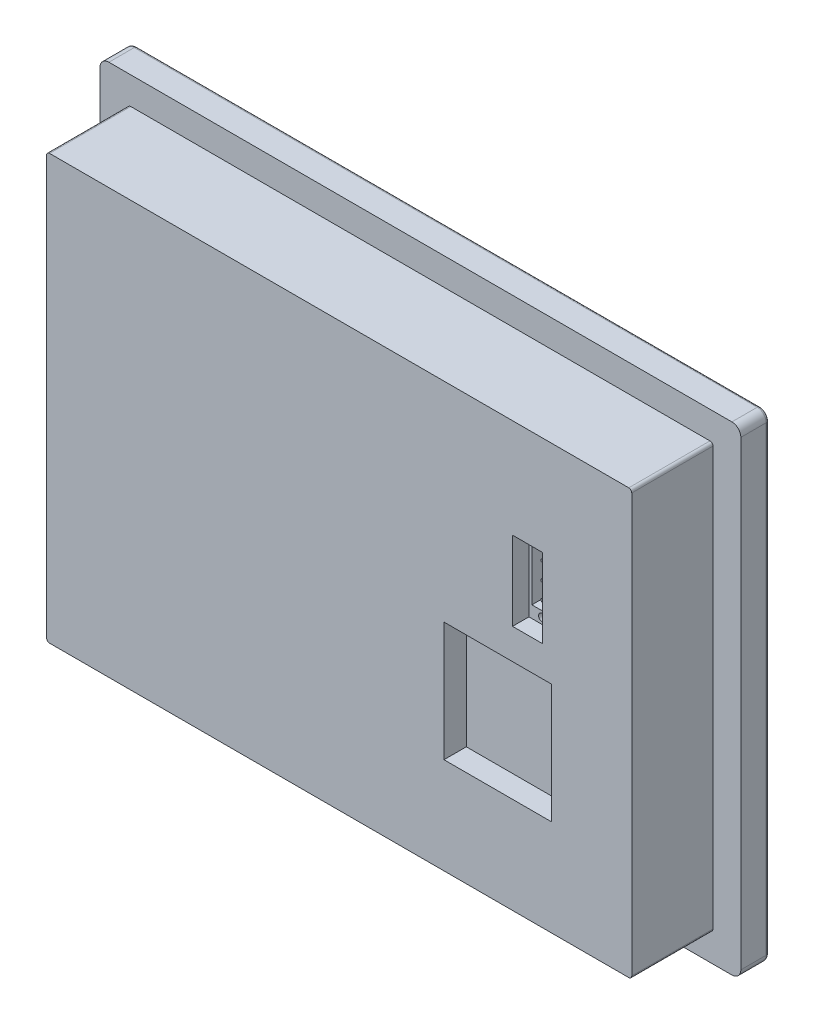
from build123d import *

# Parameters (mm, degrees)
IZIM1_W                     = 215
IZIM1_H                     = 160.7
Y_KSEKLIK_EKSTR_ZYON1_DEPTH = 9.5
IZIM2_W                     = 196.3
IZIM2_H                     = 142.3
Y_KSEKLIK_EKSTR_ZYON2_DEPTH = 27.24
IZIM3_W                     = 10
IZIM3_H                     = 26.5
IZIM3_W_2                   = 9
IZIM3_H_2                   = 25.5
KES_EKSTR_ZYON1_DEPTH       = 15
IZIM4_W                     = 9
IZIM4_H                     = 25.5
KES_EKSTR_ZYON2_DEPTH       = 5
IZIM5_R                     = 0.5
KES_EKSTR_ZYON3_DEPTH       = 5
M3_DI_LI_DELIK1_D           = 2.5
M3_DI_LI_DELIK1_DEPTH       = 8.5
M3_DI_LI_DELIK1_TIP         = 0.751075774
IZIM8_W                     = 155
IZIM8_H                     = 86
KES_EKSTR_ZYON4_DEPTH       = 0.05
KES_EKSTR_ZYON5_DEPTH       = 0.005
RADYUS1_R                   = 3
RADYUS2_R                   = 1
IZIM10_W                    = 36
IZIM10_H                    = 40
KES_EKSTR_ZYON6_DEPTH       = 7.5
RADYUS3_R                   = 1


with BuildPart() as part:
    # Çizim1 → Yükseklik-Ekstrüzyon1 (new body)
    with BuildSketch(Plane.XY):
        Rectangle(IZIM1_W, IZIM1_H)
    extrude(amount=Y_KSEKLIK_EKSTR_ZYON1_DEPTH)

    # Çizim2 → Yükseklik-Ekstrüzyon2 (add)
    with BuildSketch(Plane.XY.offset(9.5)):
        Rectangle(IZIM2_W, IZIM2_H)
    extrude(amount=Y_KSEKLIK_EKSTR_ZYON2_DEPTH)

    # Çizim3 → Kes-Ekstrüzyon1 (cut)
    with BuildSketch(Plane.XY.offset(36.74)):
        with Locations((63.15, 24.65)):
            Rectangle(IZIM3_W, IZIM3_H)
        with Locations((63.15, 24.65)):
            Rectangle(IZIM3_W_2, IZIM3_H_2, mode=Mode.SUBTRACT)
    extrude(amount=-KES_EKSTR_ZYON1_DEPTH, mode=Mode.SUBTRACT)

    # Çizim4 → Kes-Ekstrüzyon2 (cut)
    with BuildSketch(Plane.XY.offset(36.74)):
        with Locations((63.15, 24.65)):
            Rectangle(IZIM4_W, IZIM4_H)
    extrude(amount=-KES_EKSTR_ZYON2_DEPTH, mode=Mode.SUBTRACT)

    # Çizim5 → Kes-Ekstrüzyon3 (cut)
    with BuildSketch(Plane.XY.offset(31.74)):
        with BuildLine():
            Line((59.65, 33.4), (59.65, 15.9))
            Line((59.65, 15.9), (63.65, 15.9))
            ThreePointArc((63.65, 15.9), (66.618585522, 18.466987298), (64.506956825, 21.775))
            ThreePointArc((64.506956825, 21.775), (66.65, 24.65), (64.506956825, 27.525))
            ThreePointArc((64.506956825, 27.525), (66.618585522, 30.833012702), (63.65, 33.4))
            Line((63.65, 33.4), (59.65, 33.4))
        make_face()
        with Locations((63.15, 30.4)):
            Circle(IZIM5_R, mode=Mode.SUBTRACT)
        with Locations((63.15, 18.9)):
            Circle(IZIM5_R, mode=Mode.SUBTRACT)
        with Locations((63.15, 24.65)):
            Circle(IZIM5_R, mode=Mode.SUBTRACT)
    extrude(amount=-KES_EKSTR_ZYON3_DEPTH, mode=Mode.SUBTRACT)

    # M3 Dişli Delik1
    with Locations(Plane.XY.offset(31.74)):
        with Locations((63.15, 35.4), (63.15, 13.9)):
            Hole(M3_DI_LI_DELIK1_D / 2, depth=M3_DI_LI_DELIK1_DEPTH)
            with Locations((0, 0, -(M3_DI_LI_DELIK1_DEPTH + M3_DI_LI_DELIK1_TIP / 2))):  # 118° drill point
                Cone(0, M3_DI_LI_DELIK1_D / 2, M3_DI_LI_DELIK1_TIP, mode=Mode.SUBTRACT)

    # Çizim8 → Kes-Ekstrüzyon4 (cut)
    with BuildSketch(Plane(origin=(0, 0, 0), x_dir=(-1, 0, 0), z_dir=(0, 0, -1))):
        Rectangle(IZIM8_W, IZIM8_H)
    extrude(amount=-KES_EKSTR_ZYON4_DEPTH, mode=Mode.SUBTRACT)

    # Çizim9 → Kes-Ekstrüzyon5 (cut)
    with BuildSketch(Plane(origin=(0, 0, 0), x_dir=(-1, 0, 0), z_dir=(0, 0, -1))):
        with BuildLine():
            Line((-88, 61), (88, 61))
            ThreePointArc((88, 61), (90.828427125, 59.828427125), (92, 57))
            Line((92, 57), (92, -57))
            ThreePointArc((92, -57), (90.828427125, -59.828427125), (88, -61))
            Line((88, -61), (-92, -61))
            Line((-92, -61), (-92, 57))
            ThreePointArc((-92, 57), (-90.828427125, 59.828427125), (-88, 61))
        make_face()
        with BuildLine():
            Line((-88, 60), (88, 60))
            ThreePointArc((88, 60), (90.121320344, 59.121320344), (91, 57))
            Line((91, 57), (91, -57))
            ThreePointArc((91, -57), (90.121320344, -59.121320344), (88, -60))
            Line((88, -60), (-91, -60))
            Line((-91, -60), (-91, 57))
            ThreePointArc((-91, 57), (-90.121320344, 59.121320344), (-88, 60))
        make_face(mode=Mode.SUBTRACT)
    extrude(amount=-KES_EKSTR_ZYON5_DEPTH, mode=Mode.SUBTRACT)

    # Radyus1
    radyus1_edges = [part.edges().sort_by_distance(p)[0] for p in [
        (107.5, -80.35, 4.75),
        (-107.5, -80.35, 4.75),
        (-107.5, 80.35, 4.75),
        (107.5, 80.35, 4.75),
    ]]
    fillet(radyus1_edges, radius=RADYUS1_R)

    # Radyus2
    radyus2_edges = [part.edges().sort_by_distance(p)[0] for p in [
        (107.5, 0, 0),
        (0, -80.35, 0),
        (-107.5, 0, 0),
        (0, 80.35, 0),
        (106.621320344, 79.471320344, 0),
        (-106.621320344, 79.471320344, 0),
        (-106.621320344, -79.471320344, 0),
        (106.621320344, -79.471320344, 0),
    ]]
    fillet(radyus2_edges, radius=RADYUS2_R)

    # Çizim10 → Kes-Ekstrüzyon6 (cut)
    with BuildSketch(Plane.XY.offset(36.74)):
        with Locations((53.15, -18.85)):
            Rectangle(IZIM10_W, IZIM10_H)
    extrude(amount=-KES_EKSTR_ZYON6_DEPTH, mode=Mode.SUBTRACT)

    # Radyus3
    radyus3_edges = [part.edges().sort_by_distance(p)[0] for p in [
        (98.15, -71.15, 23.12),
        (98.15, 71.15, 23.12),
        (-98.15, 71.15, 23.12),
        (-98.15, -71.15, 23.12),
    ]]
    fillet(radyus3_edges, radius=RADYUS3_R)


solid = part.part
